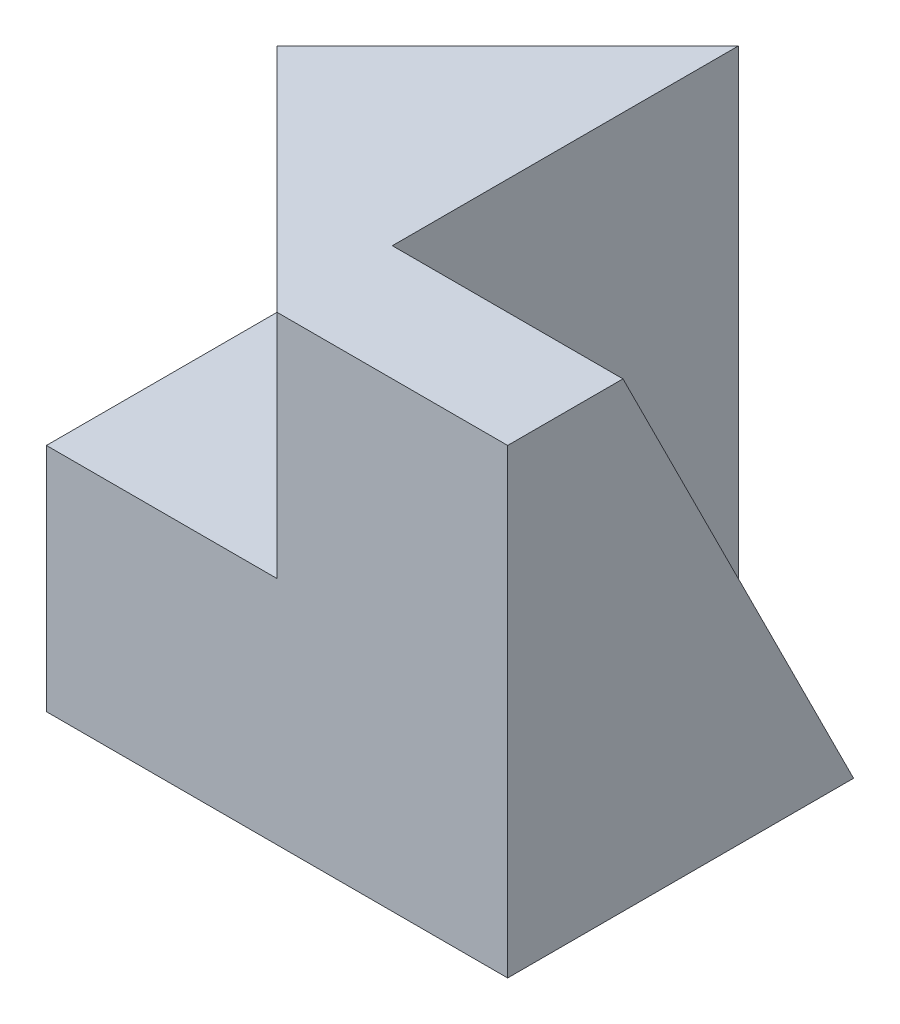
from build123d import *

# Parameters (mm, degrees)
BOSS_EXTRUDE1_DEPTH  = 40
SKETCH2_W            = 20
SKETCH2_H            = 20
BOSS_EXTRUDE3_DEPTH  = 20
CUT_EXTRUDE2_DEPTH   = 20
SKETCH5_W            = 20
SKETCH5_H            = 10
CUT_EXTRUDE3_DEPTH   = 20
CUT_EXTRUDE4_DEPTH   = 52
CUT_EXTRUDE8_DEPTH   = 20
BOSS_EXTRUDE11_DEPTH = 20


with BuildPart() as part:
    # Sketch1 → Boss-Extrude1 (new body)
    with BuildSketch(Plane.XY):
        Polygon((20, 20), (0, 20), (0, 0), (40, 0), (40, 40), (20, 40), align=None)
    extrude(amount=BOSS_EXTRUDE1_DEPTH)

    # Sketch2 → Boss-Extrude3 (add)
    with BuildSketch(Plane.ZY.offset(-20)):
        with Locations((10, 30)):
            Rectangle(SKETCH2_W, SKETCH2_H)
    extrude(amount=BOSS_EXTRUDE3_DEPTH)

    # Sketch3 → Cut-Extrude2 (cut)
    with BuildSketch(Plane(origin=(40, 0, 0), x_dir=(0, 0, -1), z_dir=(1, 0, 0))):
        Polygon((0, 0), (-20, 40), (-30, 40), align=None)
        Polygon((0, 40), (-20, 40), (0, 0), align=None)
    extrude(amount=-CUT_EXTRUDE2_DEPTH, mode=Mode.SUBTRACT)

    # Sketch5 → Cut-Extrude3 (cut)
    with BuildSketch(Plane(origin=(0, 0, 0), x_dir=(-1, 0, 0), z_dir=(0, -1, 0))):
        with Locations((-30, -5)):
            Rectangle(SKETCH5_W, SKETCH5_H)
    extrude(amount=-CUT_EXTRUDE3_DEPTH, mode=Mode.SUBTRACT)

    # Sketch6 → Cut-Extrude4 (cut)
    with BuildSketch(Plane.XZ):
        Polygon((20, 0), (0, 20), (0, 0), align=None)
    extrude(amount=-CUT_EXTRUDE4_DEPTH, mode=Mode.SUBTRACT)

    # Sketch7 → Cut-Extrude8 (cut)
    with BuildSketch(Plane(origin=(40, 0, 0), x_dir=(0, 0, -1), z_dir=(1, 0, 0))):
        Polygon((-10, 0), (-30, 40), (-10, 13.333333333), align=None)
    extrude(amount=-CUT_EXTRUDE8_DEPTH, mode=Mode.SUBTRACT)

    # Sketch14 → Boss-Extrude11 (add)
    with BuildSketch(Plane(origin=(0, 40, 0), x_dir=(1, 0, 0), z_dir=(0, 1, 0))):
        Polygon((0, -20), (20, -40), (20, -20), align=None)
    extrude(amount=-BOSS_EXTRUDE11_DEPTH)


solid = part.part
